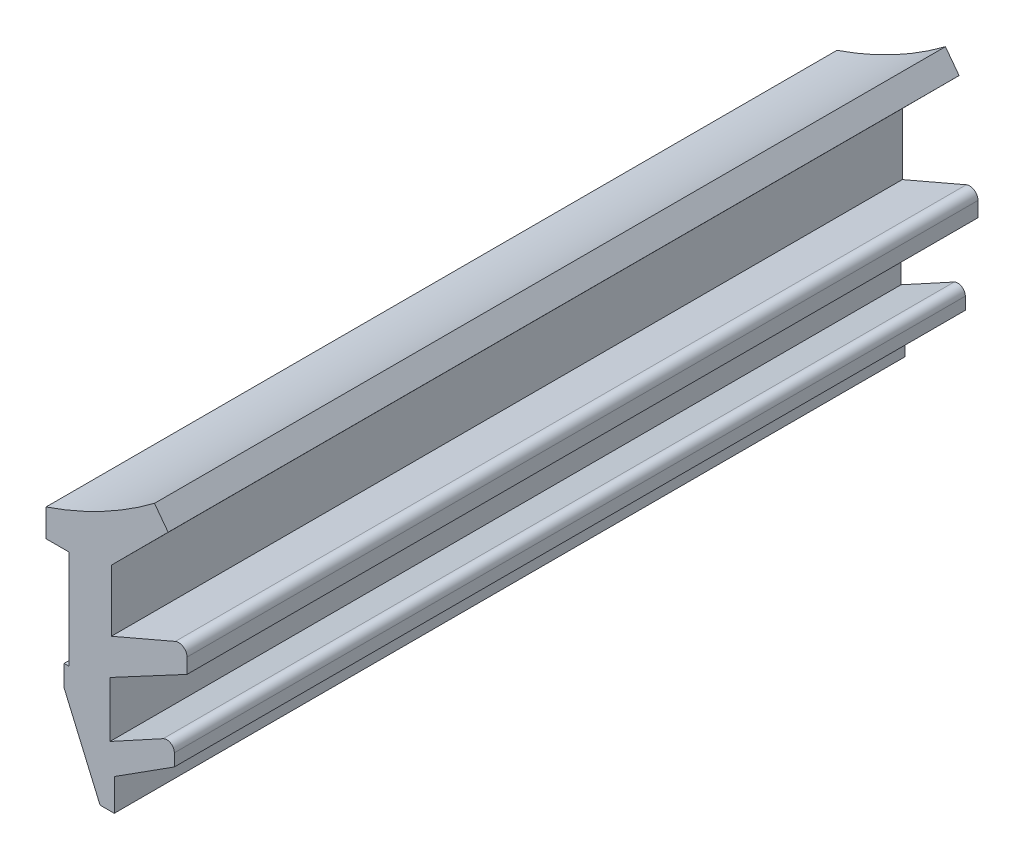
from build123d import *

# Parameters (mm, degrees)
EXTRUDE_1_DEPTH = 40


with BuildPart() as part:
    # Эскиз1 → Бобышка-Вытянуть1 (new body)
    with BuildSketch(Plane.XY):
        with BuildLine():
            Line((0, 0), (0, -5))
            Line((0, -5), (-0.235052359, -5))
            Line((-0.235052359, -5), (-0.235052359, -6.077530645))
            Line((-0.235052359, -6.077530645), (1.580879478, -10.300026718))
            Line((1.580879478, -10.300026718), (2.299876794, -10.300026718))
            Line((2.299876794, -10.300026718), (2.299876794, -8.688248945))
            Line((2.299876794, -8.688248945), (5.338733825, -6.749380382))
            Line((5.338733825, -6.749380382), (5.338733825, -6.130118817))
            ThreePointArc((5.338733825, -6.130118817), (5.151167457, -5.800618872), (4.772085378, -5.793681018))
            Line((4.772085378, -5.793681018), (2.085504308, -7.258574696))
            Line((2.085504308, -7.258574696), (2.085504308, -4.45645656))
            Line((2.085504308, -4.45645656), (5.980110004, -2.374221663))
            Line((5.980110004, -2.374221663), (5.980110004, -1.617236279))
            ThreePointArc((5.980110004, -1.617236279), (5.788765805, -1.262133881), (5.386956071, -1.226647924))
            Line((5.386956071, -1.226647924), (2.15420838, -2.616927359))
            Line((2.15420838, -2.616927359), (2.15420838, 0.497930702))
            Line((2.15420838, 0.497930702), (5.024831948, 3.373619708))
            Line((5.024831948, 3.373619708), (4.333601466, 4.294416481))
            ThreePointArc((4.333601466, 4.294416481), (1.705007112, 2.626935837), (-1.152317838, 1.391745925))
            Line((-1.152317838, 1.391745925), (-1.152317838, 0))
            Line((-1.152317838, 0), (0, 0))
        make_face()
    extrude(amount=EXTRUDE_1_DEPTH)


solid = part.part
